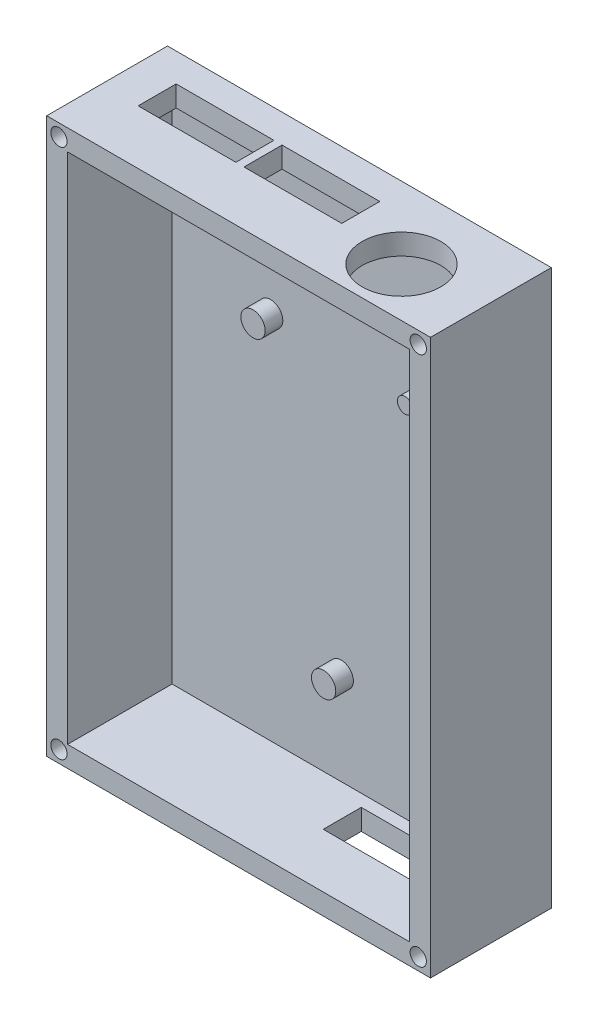
from build123d import *

# Parameters (mm, degrees)
SKETCH1_R             = 2.236067977
BOSS_EXTRUDE1_DEPTH   = 3.25
SKETCH1_R_2           = 1.414213562
BOSS_EXTRUDE1_2_DEPTH = 3.25
BOSS_EXTRUDE1_3_DEPTH = 3.25
SKETCH1_21_W          = 70.681980515
SKETCH1_21_H          = 102.181980515
BOSS_EXTRUDE2_DEPTH   = 3
SKETCH1_23_W          = 70.681980515
SKETCH1_23_H          = 102.181980515
SKETCH1_23_R          = 1.5
SKETCH1_23_W_2        = 63
SKETCH1_23_H_2        = 94.5
BOSS_EXTRUDE4_DEPTH   = 19.25
SKETCH3_R             = 7.25
SKETCH3_W             = 18
SKETCH3_H             = 7
CUT_EXTRUDE1_DEPTH    = 3.84099
SKETCH4_W             = 18
SKETCH4_H             = 7
CUT_EXTRUDE2_DEPTH    = 3.84099


with BuildPart() as part:
    # Sketch1 → Boss-Extrude1 (new body)
    with BuildSketch(Plane.XY):
        with Locations((22, 72)):
            Circle(SKETCH1_R)
    extrude(amount=BOSS_EXTRUDE1_DEPTH)



with BuildPart() as body_2:
    # Sketch1 → Boss-Extrude1 2 (new body)
    with BuildSketch(Plane.XY):
        with Locations((50, 73)):
            Circle(SKETCH1_R_2)
    extrude(amount=BOSS_EXTRUDE1_2_DEPTH)


with BuildPart() as body_3:
    # Sketch1 → Boss-Extrude1 3 (new body)
    with BuildSketch(Plane.XY):
        with Locations((35, 21)):
            Circle(SKETCH1_R)
    extrude(amount=BOSS_EXTRUDE1_3_DEPTH)


with BuildPart() as part_1:
    add(part.part)

    add(body_2.part)  # Boss-Extrude2 merges body 2

    add(body_3.part)  # Boss-Extrude2 merges body 3
    # Sketch1_21 → Boss-Extrude2 (add)
    with BuildSketch(Plane.XY):
        with Locations((35.340990258, 51.090990258)):
            Rectangle(SKETCH1_21_W, SKETCH1_21_H)
    extrude(amount=-BOSS_EXTRUDE2_DEPTH)

    # Sketch1_23 → Boss-Extrude4 (add)
    with BuildSketch(Plane.XY):
        with Locations((35.340990258, 51.090990258)):
            Rectangle(SKETCH1_23_W, SKETCH1_23_H)
        with BuildLine():
            ThreePointArc((3.75, 2.25), (0.864180701, 1.675974851), (3.310660172, 3.310660172))
            ThreePointArc((3.310660172, 3.310660172), (3.635819299, 2.824025149), (3.75, 2.25))
        make_face(mode=Mode.SUBTRACT)
        with Locations((68.431980515, 2.25)):
            Circle(SKETCH1_23_R, mode=Mode.SUBTRACT)
        with Locations((2.25, 99.931980515)):
            Circle(SKETCH1_23_R, mode=Mode.SUBTRACT)
        with Locations((35.340990258, 51.090990258)):
            Rectangle(SKETCH1_23_W_2, SKETCH1_23_H_2, mode=Mode.SUBTRACT)
        with Locations((68.431980515, 99.931980515)):
            Circle(SKETCH1_23_R, mode=Mode.SUBTRACT)
    extrude(amount=BOSS_EXTRUDE4_DEPTH)

    # Sketch3 → Cut-Extrude1 (cut)
    with BuildSketch(Plane.XZ.offset(-98.340990258)):
        with Locations((56.340990258, 10.25)):
            Circle(SKETCH3_R)
        with Locations((15.840990258, 5.75)):
            Rectangle(SKETCH3_W, SKETCH3_H)
        with Locations((35.340990258, 5.75)):
            Rectangle(SKETCH3_W, SKETCH3_H)
    extrude(amount=-CUT_EXTRUDE1_DEPTH, mode=Mode.SUBTRACT)

    # Sketch4 → Cut-Extrude2 (cut)
    with BuildSketch(Plane.XZ):
        with Locations((49.931980515, 5.75)):
            Rectangle(SKETCH4_W, SKETCH4_H)
    extrude(amount=-CUT_EXTRUDE2_DEPTH, mode=Mode.SUBTRACT)


solid = part_1.part
